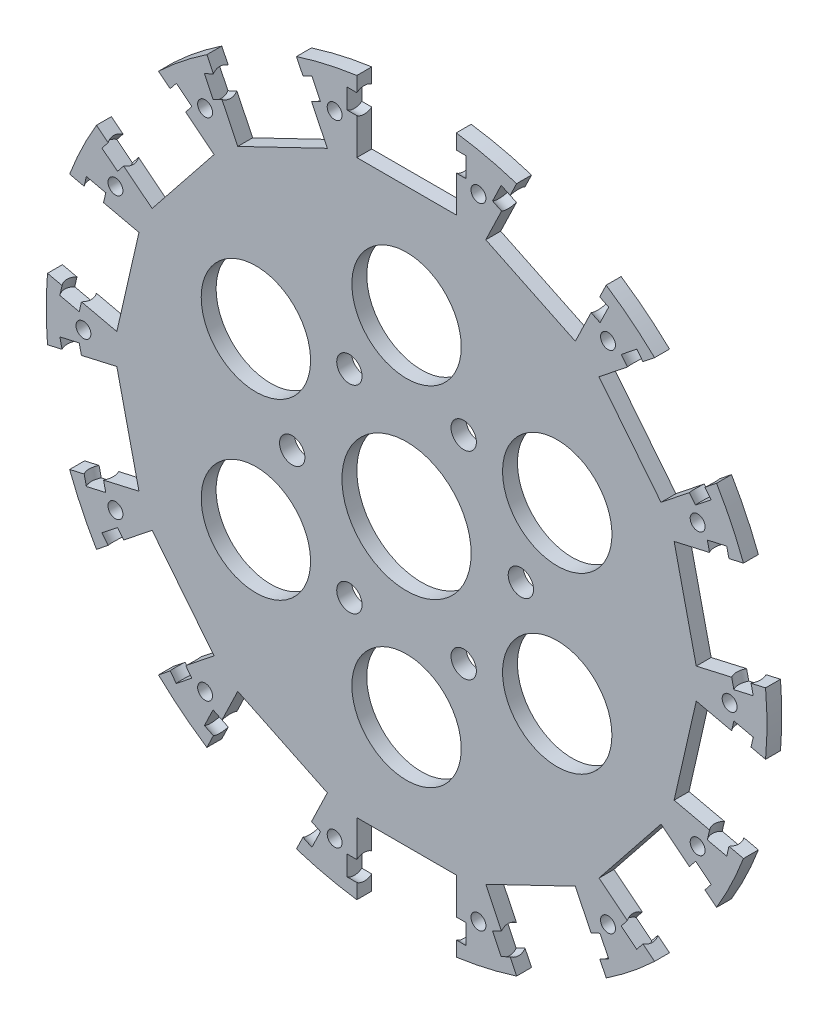
from build123d import *

# Parameters (mm, degrees)
SKETCH_1_R               = 47.5
EXTRUDE_1_DEPTH          = 3
SKETCH_2_R               = 11
CUT_EXTRUDE_1_DEPTH      = 4
PATTERN_CIRCULAR_1_COUNT = 6
SKETCH_3_R               = 2.55
CUT_EXTRUDE_2_DEPTH      = 4
PATTERN_CIRCULAR_2_COUNT = 6
SKETCH_4_R               = 13
CUT_EXTRUDE_3_DEPTH      = 4
SKETCH_5_R               = 72.5
SKETCH_5_R_2             = 47.5
EXTRUDE_2_DEPTH          = 3
SKETCH_6_W               = 20
SKETCH_6_H               = 30
CUT_EXTRUDE_4_DEPTH      = 4
PATTERN_CIRCULAR_3_COUNT = 14
SKETCH_7_R               = 1.5
CUT_EXTRUDE_5_DEPTH      = 4
PATTERN_CIRCULAR_4_COUNT = 14
SKETCH_8_R               = 2.5
CUT_EXTRUDE_6_DEPTH      = 2
SKETCH_9_R               = 2.5
CUT_EXTRUDE_7_DEPTH      = 2
PATTERN_CIRCULAR_5_COUNT = 14


with BuildPart() as part:
    # 草图1 → 凸台-拉伸1 (new body)
    with BuildSketch(Plane.XY):
        Circle(SKETCH_1_R)
    extrude(amount=EXTRUDE_1_DEPTH)

    # 草图2 → 切除-拉伸1 (cut, through all)
    with BuildSketch(Plane.XY.offset(3)):
        with Locations((0, 35)):
            Circle(SKETCH_2_R)
    cut_extrude_1 = extrude(amount=-CUT_EXTRUDE_1_DEPTH, mode=Mode.SUBTRACT)

    # 阵列(圆周)1: 切除-拉伸1 ×6 about axis
    pattern_circular_1_axis = Axis((0, 0, 0), (0, 0, 1))
    for i in range(1, PATTERN_CIRCULAR_1_COUNT):
        add(cut_extrude_1.rotate(pattern_circular_1_axis, i * 360 / PATTERN_CIRCULAR_1_COUNT), mode=Mode.SUBTRACT)

    # 草图3 → 切除-拉伸2 (cut, through all)
    with BuildSketch(Plane.XY.offset(3)):
        with Locations((11.5, 19.918584287)):
            Circle(SKETCH_3_R)
    cut_extrude_2 = extrude(amount=-CUT_EXTRUDE_2_DEPTH, mode=Mode.SUBTRACT)

    # 阵列(圆周)2: 切除-拉伸2 ×6 about axis
    pattern_circular_2_axis = Axis((0, 0, 0), (0, 0, 1))
    for i in range(1, PATTERN_CIRCULAR_2_COUNT):
        add(cut_extrude_2.rotate(pattern_circular_2_axis, i * 360 / PATTERN_CIRCULAR_2_COUNT), mode=Mode.SUBTRACT)

    # 草图4 → 切除-拉伸3 (cut, through all)
    with BuildSketch(Plane.XY.offset(3)):
        Circle(SKETCH_4_R)
    extrude(amount=-CUT_EXTRUDE_3_DEPTH, mode=Mode.SUBTRACT)

    # 草图5 → 凸台-拉伸2 (add)
    with BuildSketch(Plane.XY.offset(3)):
        Circle(SKETCH_5_R)
        Circle(SKETCH_5_R_2, mode=Mode.SUBTRACT)
    extrude(amount=-EXTRUDE_2_DEPTH)

    # 草图6 → 切除-拉伸4 (cut, through all)
    with BuildSketch(Plane(origin=(0, 0, 0), x_dir=(-1, 0, 0), z_dir=(0, 0, -1))):
        with Locations((0, 72.5)):
            Rectangle(SKETCH_6_W, SKETCH_6_H)
    cut_extrude_4 = extrude(amount=-CUT_EXTRUDE_4_DEPTH, mode=Mode.SUBTRACT)

    # 阵列(圆周)3: 切除-拉伸4 ×14 about axis
    pattern_circular_3_axis = Axis((0, 0, 0), (0, 0, 1))
    for i in range(1, PATTERN_CIRCULAR_3_COUNT):
        add(cut_extrude_4.rotate(pattern_circular_3_axis, i * 360 / PATTERN_CIRCULAR_3_COUNT), mode=Mode.SUBTRACT)

    # 草图7 → 切除-拉伸5 (cut, through all)
    with BuildSketch(Plane.XY.offset(3)):
        with Locations((-14.463860707, 63.370314292)):
            Circle(SKETCH_7_R)
    cut_extrude_5 = extrude(amount=-CUT_EXTRUDE_5_DEPTH, mode=Mode.SUBTRACT)

    # 阵列(圆周)4: 切除-拉伸5 ×14 about axis
    pattern_circular_4_axis = Axis((0, 0, 0), (0, 0, 1))
    for i in range(1, PATTERN_CIRCULAR_4_COUNT):
        add(cut_extrude_5.rotate(pattern_circular_4_axis, i * 360 / PATTERN_CIRCULAR_4_COUNT), mode=Mode.SUBTRACT)

    # 草图8 → 切除-拉伸6 (cut)
    with BuildSketch(Plane(origin=(9.009688679, 4.338837391, 0), x_dir=(0, 0, 1), z_dir=(-0.900968868, -0.433883739, 0))):
        with Locations((1.5, 66.807033082)):
            Circle(SKETCH_8_R)
    cut_extrude_6 = extrude(amount=-CUT_EXTRUDE_6_DEPTH, mode=Mode.SUBTRACT)

    # 草图9 → 切除-拉伸7 (cut)
    with BuildSketch(Plane(origin=(-10, 0, 0), x_dir=(0, 0, -1), z_dir=(1, 0, 0))):
        with Locations((-1.5, 66.807033082)):
            Circle(SKETCH_9_R)
    cut_extrude_7 = extrude(amount=-CUT_EXTRUDE_7_DEPTH, mode=Mode.SUBTRACT)

    # 阵列(圆周)5: 切除-拉伸6, 切除-拉伸7 ×14 about axis
    pattern_circular_5_axis = Axis((0, 0, 0), (0, 0, 1))
    for i in range(1, PATTERN_CIRCULAR_5_COUNT):
        add(cut_extrude_6.rotate(pattern_circular_5_axis, i * 360 / PATTERN_CIRCULAR_5_COUNT), mode=Mode.SUBTRACT)
        add(cut_extrude_7.rotate(pattern_circular_5_axis, i * 360 / PATTERN_CIRCULAR_5_COUNT), mode=Mode.SUBTRACT)


solid = part.part
